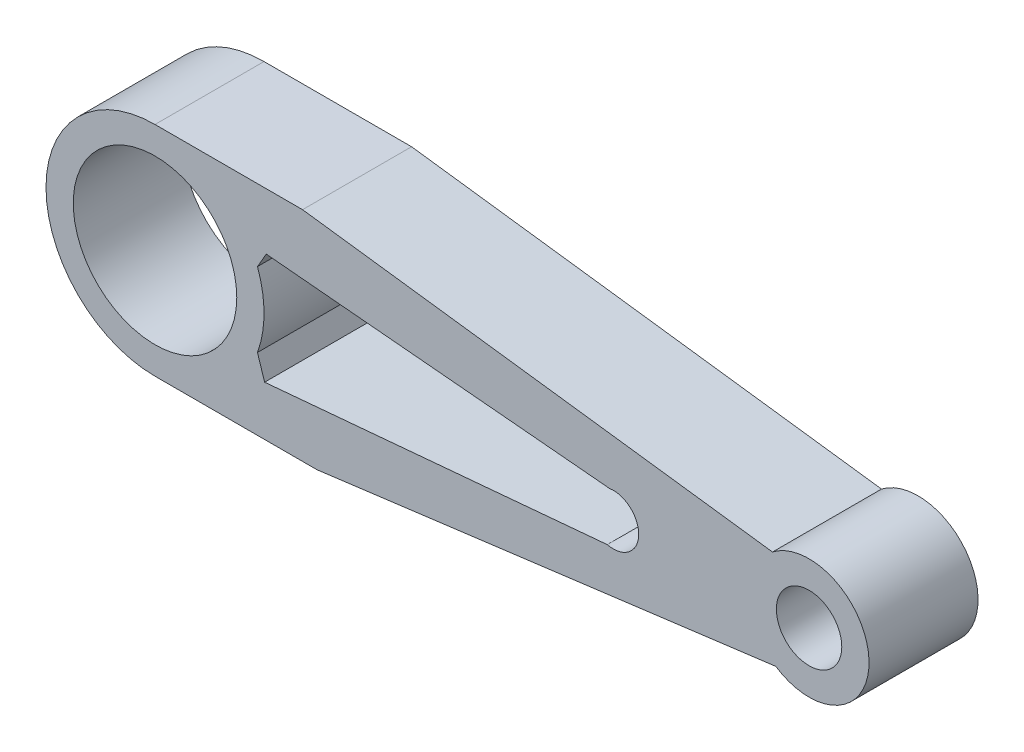
from build123d import *

# Parameters (mm, degrees)
SZKIC2_R                    = 20
SZKIC2_R_2                  = 15
SZKIC2_R_3                  = 11
SZKIC2_R_4                  = 6
DODANIE_WYCI_GNI_CIE2_DEPTH = 20


with BuildPart() as part:
    # Szkic2 → Dodanie-wyciągnięcie2 (new body)
    with BuildSketch(Plane.XY):
        with BuildLine():
            ThreePointArc((18.800305478, -6.822647135), (11.479265162, -16.377621053), (0, -20))
            Line((0, -20), (29.733250719, -20))
            Line((29.733250719, -20), (113.904224342, -9.156501468))
            ThreePointArc((113.904224342, -9.156501468), (109.006471259, -0.377260954), (113.290863107, 8.71707991))
            Line((113.290863107, 8.71707991), (27.069867273, 20))
            Line((27.069867273, 20), (0, 20))
            ThreePointArc((0, 20), (11.479265162, 16.377621053), (18.800305478, 6.822647135))
            Line((18.800305478, 6.822647135), (20.410663052, 9.615363763))
            Line((20.410663052, 9.615363763), (83.386650307, 3.862118667))
            ThreePointArc((83.386650307, 3.862118667), (88.740074522, -0.948230099), (82.9809258, -5.26457254))
            Line((82.9809258, -5.26457254), (20.107259976, -10.897738547))
            Line((20.107259976, -10.897738547), (18.800305478, -6.822647135))
        make_face()
        Circle(SZKIC2_R)
        Circle(SZKIC2_R_2, mode=Mode.SUBTRACT)
        with Locations((120, 0)):
            Circle(SZKIC2_R_3)
        with Locations((120, 0)):
            Circle(SZKIC2_R_4, mode=Mode.SUBTRACT)
    extrude(amount=DODANIE_WYCI_GNI_CIE2_DEPTH)


solid = part.part
